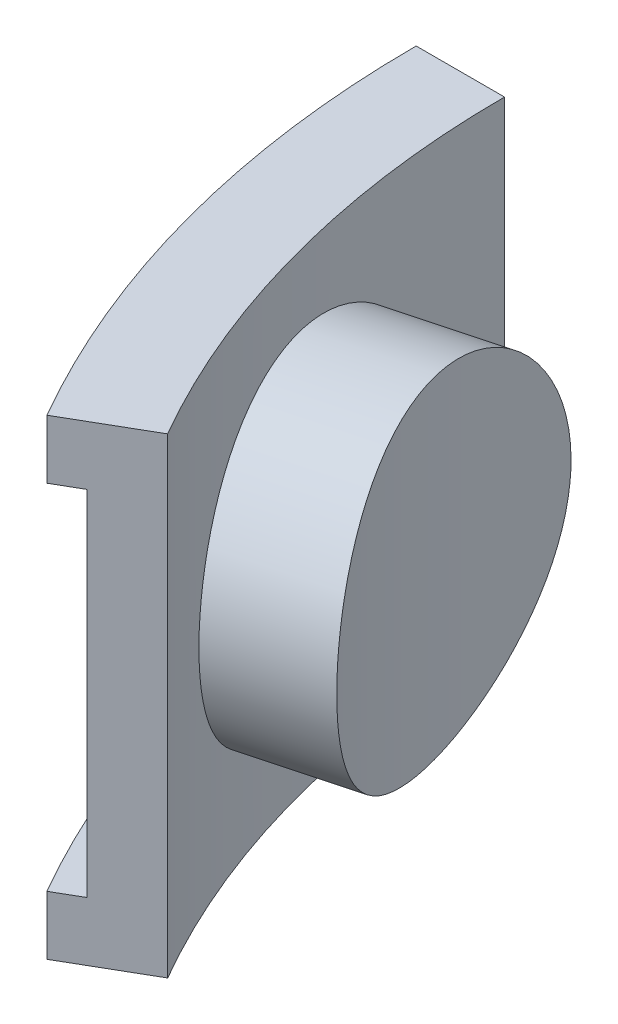
from build123d import *

# Parameters (mm, degrees)
REVOLVE1_ANGLE      = 30
SKETCH2_R           = 7.14375
BOSS_EXTRUDE1_DEPTH = 2.54
SKETCH3_R           = 7.14375
BOSS_EXTRUDE2_DEPTH = 6.35
SKETCH4_W           = 34.925
SKETCH4_H           = 20.32
CUT_REVOLVE1_ANGLE  = 30


with BuildPart() as part:
    # Sketch1 → Revolve1 (revolve)
    with BuildSketch(Plane.XY):
        Polygon((-43.4975, 0), (-43.4975, 2.54), (-42.2275, 2.54), (-42.2275, 17.78), (-43.4975, 17.78), (-43.4975, 20.32), (-39.6875, 20.32), (-39.6875, 0), align=None)
    revolve(axis=Axis((0, 0, 0), (0, 1, 0)), revolution_arc=REVOLVE1_ANGLE)

    # Sketch2 → Boss-Extrude1 (add)
    with BuildSketch(Plane(origin=(-37.028941606, 0, 9.921875), x_dir=(0.258819045, 0, 0.965925826), z_dir=(-0.965925826, 0, 0.258819045))):
        with Locations((0, 10.16)):
            Circle(SKETCH2_R)
    extrude(amount=BOSS_EXTRUDE1_DEPTH)

    # Sketch3 → Boss-Extrude2 (add)
    with BuildSketch(Plane(origin=(-37.028941606, 0, 9.921875), x_dir=(-0.258819045, 0, -0.965925826), z_dir=(0.965925826, 0, -0.258819045))):
        with Locations((0, 10.16)):
            Circle(SKETCH3_R)
    extrude(amount=BOSS_EXTRUDE2_DEPTH)

    # Sketch4 → Cut-Revolve1 (revolve, cut)
    with BuildSketch(Plane.XY):
        with Locations((-17.4625, 10.16)):
            Rectangle(SKETCH4_W, SKETCH4_H)
    revolve(axis=Axis((0, 0, 0), (0, 1, 0)), revolution_arc=CUT_REVOLVE1_ANGLE, mode=Mode.SUBTRACT)


solid = part.part
